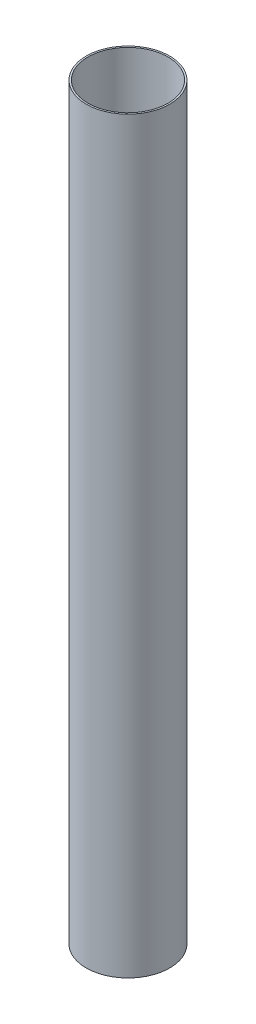
from build123d import *

# Parameters (mm, degrees)
SKETCH2_R           = 79.375
SKETCH2_R_2         = 76.2
BOSS_EXTRUDE1_DEPTH = 1422.4


with BuildPart() as part:
    # Sketch2 → Boss-Extrude1 (new body)
    with BuildSketch(Plane(origin=(0, 0, 0), x_dir=(1, 0, 0), z_dir=(0, 1, 0))):
        Circle(SKETCH2_R)
        Circle(SKETCH2_R_2, mode=Mode.SUBTRACT)
    extrude(amount=BOSS_EXTRUDE1_DEPTH)


solid = part.part
